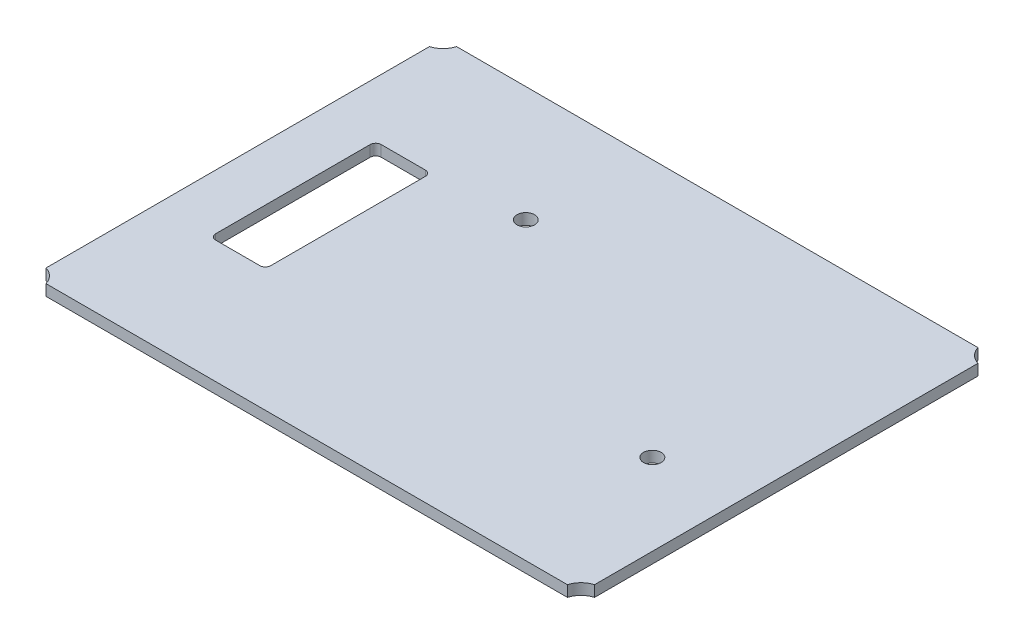
from build123d import *

# Parameters (mm, degrees)
BOSS_EXTRUDE1_DEPTH = 2
SKETCH2_W           = 10
SKETCH2_H           = 30
CUT_EXTRUDE1_DEPTH  = 3
FILLET1_R           = 1
CUT_EXTRUDE2_REACH  = 4
SKETCH3_R           = 1.6


with BuildPart() as part:
    # Sketch1 → Boss-Extrude1 (new body)
    with BuildSketch(Plane(origin=(0, 0, 0), x_dir=(1, 0, 0), z_dir=(0, 1, 0))):
        with BuildLine():
            ThreePointArc((-49.7, -34.741676707), (-48.154415588, -35.654415588), (-47.241676707, -37.2))
            Line((-47.241676707, -37.2), (47.241676707, -37.2))
            ThreePointArc((47.241676707, -37.2), (48.154415588, -35.654415588), (49.7, -34.741676707))
            Line((49.7, -34.741676707), (49.7, 34.741676707))
            ThreePointArc((49.7, 34.741676707), (48.154415588, 35.654415588), (47.241676707, 37.2))
            Line((47.241676707, 37.2), (-47.241676707, 37.2))
            ThreePointArc((-47.241676707, 37.2), (-48.154415588, 35.654415588), (-49.7, 34.741676707))
            Line((-49.7, 34.741676707), (-49.7, -34.741676707))
        make_face()
    extrude(amount=BOSS_EXTRUDE1_DEPTH)

    # Sketch2 → Cut-Extrude1 (cut, through all)
    with BuildSketch(Plane(origin=(0, 2, 0), x_dir=(1, 0, 0), z_dir=(0, 1, 0))):
        with Locations((-34.7, 0)):
            Rectangle(SKETCH2_W, SKETCH2_H)
    extrude(amount=-CUT_EXTRUDE1_DEPTH, mode=Mode.SUBTRACT)

    # Fillet1
    fillet1_edges = [part.edges().sort_by_distance(p)[0] for p in [
        (-29.7, 1, -15),
        (-29.7, 1, 15),
        (-39.7, 1, 15),
        (-39.7, 1, -15),
    ]]
    fillet(fillet1_edges, radius=FILLET1_R)

    # Sketch3 → Cut-Extrude2 (cut, up to next)
    with BuildSketch(Plane(origin=(0, 2, 0), x_dir=(1, 0, 0), z_dir=(0, 1, 0)), mode=Mode.PRIVATE) as cut_extrude2_sk1:
        with Locations((-13.794673406, 16.290721811)):
            Circle(SKETCH3_R)
    cut_extrude2_tool1 = extrude(cut_extrude2_sk1.sketch, amount=-CUT_EXTRUDE2_REACH, mode=Mode.PRIVATE) & part.part
    add(cut_extrude2_tool1.solids().sort_by_distance((-13.794673, 2, -16.290722))[0], mode=Mode.SUBTRACT)
    # Sketch3 → Cut-Extrude2 (cut, up to next)
    with BuildSketch(Plane(origin=(0, 2, 0), x_dir=(1, 0, 0), z_dir=(0, 1, 0)), mode=Mode.PRIVATE) as cut_extrude2_sk2:
        with Locations((34.973326594, -9.541278189)):
            Circle(SKETCH3_R)
    cut_extrude2_tool2 = extrude(cut_extrude2_sk2.sketch, amount=-CUT_EXTRUDE2_REACH, mode=Mode.PRIVATE) & part.part
    add(cut_extrude2_tool2.solids().sort_by_distance((34.973327, 2, 9.541278))[0], mode=Mode.SUBTRACT)


solid = part.part
